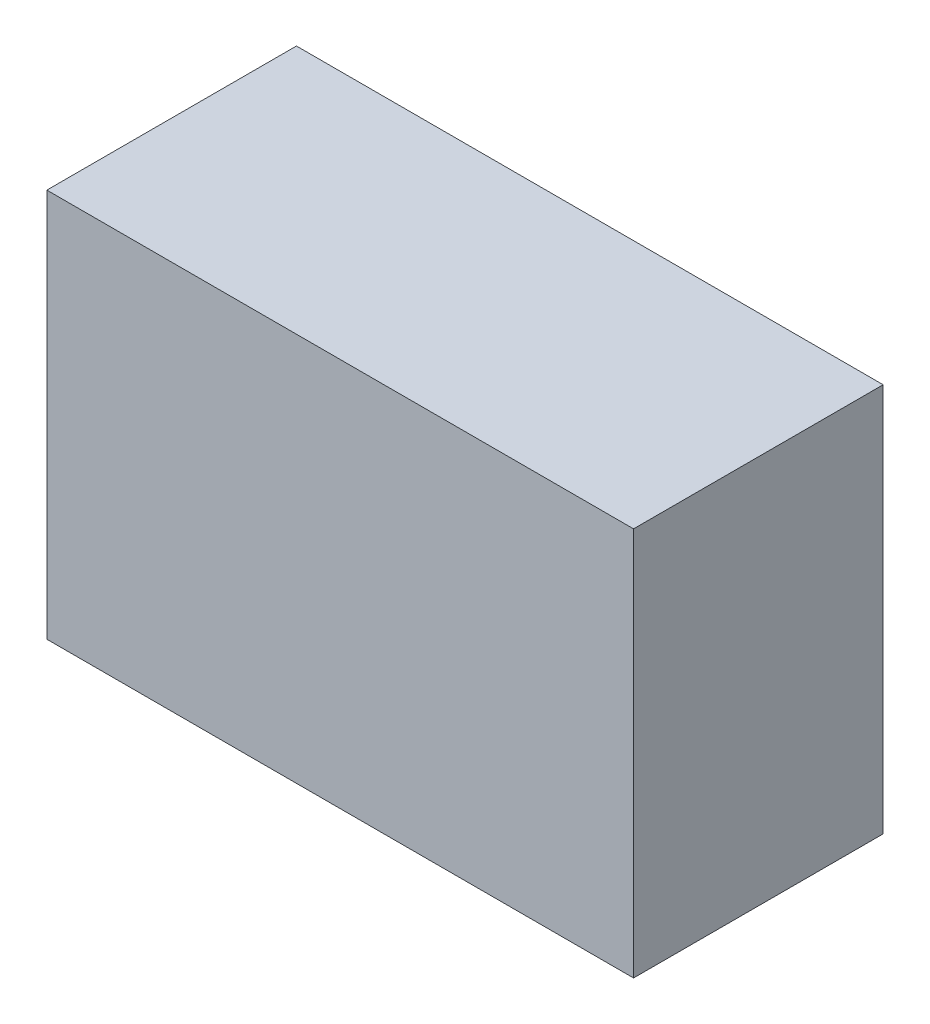
from build123d import *

# Parameters (mm, degrees)
ESBO_O1_W                = 90.5
ESBO_O1_H                = 60
RESSALTO_EXTRUS_O1_DEPTH = 38.5


with BuildPart() as part:
    # Esboço1 → Ressalto-extrusão1 (new body)
    with BuildSketch(Plane.XY):
        with Locations((3.336420871, -1.905084746)):
            Rectangle(ESBO_O1_W, ESBO_O1_H)
    extrude(amount=RESSALTO_EXTRUS_O1_DEPTH)


solid = part.part
